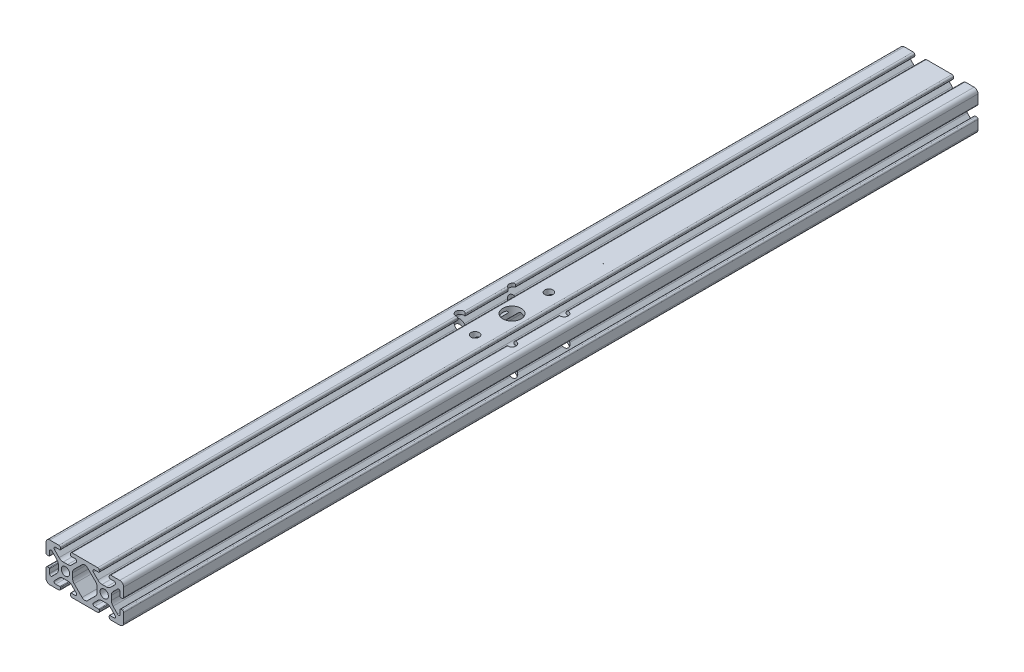
from build123d import *

# Parameters (mm, degrees)
SKIZZE1_R                       = 2.15
AUFSATZ_LINEAR_AUSTRAGEN1_DEPTH = 440
SKIZZE2_R                       = 4.747316715
SCHNITT_LINEAR_AUSTRAGEN1_DEPTH = 21
M5_GEWINDEBOHRUNG1_D            = 4.2


with BuildPart() as part:
    # Skizze1 → Aufsatz-Linear austragen1 (new body)
    with BuildSketch(Plane.XY.offset(1000)):
        with BuildLine():
            Line((24.824997674, -12.875), (24.824997674, -15.044122712))
            ThreePointArc((24.824997674, -15.044122712), (24.343490565, -15.764748956), (23.49345395, -15.595666041))
            Line((23.49345395, -15.595666041), (21.153677342, -13.25588859))
            ThreePointArc((21.153677342, -13.25588859), (20.503359366, -12.282618676), (20.274998067, -11.134568629))
            Line((20.274998067, -11.134568629), (20.274998067, -8.865431267))
            ThreePointArc((20.274998067, -8.865431267), (20.503359366, -7.717381221), (21.153677339, -6.744111308))
            Line((21.153677339, -6.744111308), (23.493453719, -4.404334079))
            ThreePointArc((23.493453719, -4.404334079), (24.343490481, -4.235251133), (24.824997674, -4.955877502))
            Line((24.824997674, -4.955877502), (24.824997674, -7.124999805))
            ThreePointArc((24.824997674, -7.124999805), (24.912865697, -7.337131977), (25.12499787, -7.425))
            Line((25.12499787, -7.425), (25.825, -7.425))
            ThreePointArc((25.825, -7.425), (26.390685425, -7.190685425), (26.625, -6.625))
            Line((26.625, -6.625), (26.625, -2))
            ThreePointArc((26.625, -2), (26.039213562, -0.585786438), (24.625, 0))
            Line((24.625, 0), (19.999999697, 0))
            ThreePointArc((19.999999697, 0), (19.434314272, -0.234314575), (19.199999697, -0.8))
            Line((19.199999697, -0.8), (19.199999697, -1.499999434))
            ThreePointArc((19.199999697, -1.499999434), (19.287867662, -1.712131468), (19.499999697, -1.799999434))
            Line((19.499999697, -1.799999434), (21.669123246, -1.799999434))
            ThreePointArc((21.669123246, -1.799999434), (22.389750472, -2.281507199), (22.220667326, -3.131544972))
            Line((22.220667326, -3.131544972), (19.880890601, -5.471320847))
            ThreePointArc((19.880890601, -5.471320847), (18.907620688, -6.12163882), (17.759570643, -6.350000119))
            Line((17.759570643, -6.350000119), (15.490432362, -6.350000119))
            ThreePointArc((15.490432362, -6.350000119), (14.342381815, -6.121638613), (13.369111636, -5.47132008))
            Line((13.369111636, -5.47132008), (11.029335023, -3.131542624))
            ThreePointArc((11.029335023, -3.131542624), (10.860252403, -2.281506292), (11.580878411, -1.799999434))
            Line((11.580878411, -1.799999434), (13.749999805, -1.799999434))
            ThreePointArc((13.749999805, -1.799999434), (13.962131977, -1.712131411), (14.05, -1.499999239))
            Line((14.05, -1.499999239), (14.05, -0.8))
            ThreePointArc((14.05, -0.8), (13.815685425, -0.234314575), (13.25, 0))
            Line((13.25, 0), (-3.05e-07, 0))
            ThreePointArc((-3.05e-07, 0), (-0.56568573, -0.234314575), (-0.800000305, -0.8))
            Line((-0.800000305, -0.8), (-0.800000305, -1.499999434))
            ThreePointArc((-0.800000305, -1.499999434), (-0.71213234, -1.712131468), (-0.500000305, -1.799999434))
            Line((-0.500000305, -1.799999434), (1.669123789, -1.799999434))
            ThreePointArc((1.669123789, -1.799999434), (2.389750739, -2.281507015), (2.220667658, -3.131544464))
            Line((2.220667658, -3.131544464), (-0.119109575, -5.471320847))
            ThreePointArc((-0.119109575, -5.471320847), (-1.092379488, -6.12163882), (-2.240429534, -6.350000119))
            Line((-2.240429534, -6.350000119), (-4.50956764, -6.350000119))
            ThreePointArc((-4.50956764, -6.350000119), (-5.657618189, -6.121638612), (-6.630888368, -5.471320077))
            Line((-6.630888368, -5.471320077), (-8.970664973, -3.131542623))
            ThreePointArc((-8.970664973, -3.131542623), (-9.139747592, -2.281506291), (-8.419121584, -1.799999434))
            Line((-8.419121584, -1.799999434), (-6.250000197, -1.799999434))
            ThreePointArc((-6.250000197, -1.799999434), (-6.037868023, -1.712131411), (-5.95, -1.499999237))
            Line((-5.95, -1.499999237), (-5.95, -0.8))
            ThreePointArc((-5.95, -0.8), (-6.184314575, -0.234314575), (-6.75, 0))
            Line((-6.75, 0), (-11.375, 0))
            ThreePointArc((-11.375, 0), (-12.789213562, -0.585786438), (-13.375, -2))
            Line((-13.375, -2), (-13.375, -6.625))
            ThreePointArc((-13.375, -6.625), (-13.140685425, -7.190685425), (-12.575, -7.425))
            Line((-12.575, -7.425), (-11.875000566, -7.425))
            ThreePointArc((-11.875000566, -7.425), (-11.662868532, -7.337132034), (-11.575000566, -7.125))
            Line((-11.575000566, -7.125), (-11.575000566, -4.955878914))
            ThreePointArc((-11.575000566, -4.955878914), (-11.093493588, -4.235252725), (-10.243457043, -4.404335387))
            Line((-10.243457043, -4.404335387), (-7.90367992, -6.744111667))
            ThreePointArc((-7.90367992, -6.744111667), (-7.253361387, -7.717381846), (-7.024999881, -8.865432393))
            Line((-7.024999881, -8.865432393), (-7.024999881, -11.13456764))
            ThreePointArc((-7.024999881, -11.13456764), (-7.253361388, -12.282618189), (-7.903679923, -13.255888368))
            Line((-7.903679923, -13.255888368), (-10.243457377, -15.595664973))
            ThreePointArc((-10.243457377, -15.595664973), (-11.093493709, -15.764747592), (-11.575000566, -15.044121584))
            Line((-11.575000566, -15.044121584), (-11.575000566, -12.875000197))
            ThreePointArc((-11.575000566, -12.875000197), (-11.662868589, -12.662868023), (-11.875000763, -12.575))
            Line((-11.875000763, -12.575), (-12.575, -12.575))
            ThreePointArc((-12.575, -12.575), (-13.140685425, -12.809314575), (-13.375, -13.375))
            Line((-13.375, -13.375), (-13.375, -18))
            ThreePointArc((-13.375, -18), (-12.789213562, -19.414213562), (-11.375, -20))
            Line((-11.375, -20), (-6.75, -20))
            ThreePointArc((-6.75, -20), (-6.184314575, -19.765685425), (-5.95, -19.2))
            Line((-5.95, -19.2), (-5.95, -18.500000763))
            ThreePointArc((-5.95, -18.500000763), (-6.037867966, -18.287868729), (-6.25, -18.200000763))
            Line((-6.25, -18.200000763), (-8.419121391, -18.200000763))
            ThreePointArc((-8.419121391, -18.200000763), (-9.13974758, -17.718493784), (-8.970664918, -16.868457239))
            Line((-8.970664918, -16.868457239), (-6.630888309, -14.528679787))
            ThreePointArc((-6.630888309, -14.528679787), (-5.65761813, -13.878361254), (-4.509567583, -13.649999749))
            Line((-4.509567583, -13.649999749), (-2.24042972, -13.649999749))
            ThreePointArc((-2.24042972, -13.649999749), (-1.092379673, -13.878361048), (-0.11910976, -14.528679023))
            Line((-0.11910976, -14.528679023), (2.220668033, -16.868455972))
            ThreePointArc((2.220668033, -16.868455972), (2.389751083, -17.718493268), (1.669124262, -18.200000763))
            Line((1.669124262, -18.200000763), (-0.500000109, -18.200000763))
            ThreePointArc((-0.500000109, -18.200000763), (-0.712132282, -18.287868786), (-0.800000305, -18.50000096))
            Line((-0.800000305, -18.50000096), (-0.800000305, -19.2))
            ThreePointArc((-0.800000305, -19.2), (-0.56568573, -19.765685425), (-3.05e-07, -20))
            Line((-3.05e-07, -20), (13.25, -20))
            ThreePointArc((13.25, -20), (13.815685425, -19.765685425), (14.05, -19.2))
            Line((14.05, -19.2), (14.05, -18.500000763))
            ThreePointArc((14.05, -18.500000763), (13.962132034, -18.287868729), (13.75, -18.200000763))
            Line((13.75, -18.200000763), (11.580878614, -18.200000763))
            ThreePointArc((11.580878614, -18.200000763), (10.860252424, -17.718493784), (11.029335085, -16.868457238))
            Line((11.029335085, -16.868457238), (13.369111683, -14.52867979))
            ThreePointArc((13.369111683, -14.52867979), (14.342381863, -13.878361255), (15.490432412, -13.649999749))
            Line((15.490432412, -13.649999749), (17.759570633, -13.649999749))
            ThreePointArc((17.759570633, -13.649999749), (18.907620681, -13.878361048), (19.880890596, -14.528679023))
            Line((19.880890596, -14.528679023), (22.220667763, -16.868455348))
            ThreePointArc((22.220667763, -16.868455348), (22.389750893, -17.718493043), (21.669123734, -18.200000763))
            Line((21.669123734, -18.200000763), (19.499999892, -18.200000763))
            ThreePointArc((19.499999892, -18.200000763), (19.287867719, -18.287868786), (19.199999697, -18.500000958))
            Line((19.199999697, -18.500000958), (19.199999697, -19.2))
            ThreePointArc((19.199999697, -19.2), (19.434314272, -19.765685425), (19.999999697, -20))
            Line((19.999999697, -20), (24.625, -20))
            ThreePointArc((24.625, -20), (26.039213562, -19.414213562), (26.625, -18))
            Line((26.625, -18), (26.625, -13.375))
            ThreePointArc((26.625, -13.375), (26.390685425, -12.809314575), (25.825, -12.575))
            Line((25.825, -12.575), (25.124997674, -12.575))
            ThreePointArc((25.124997674, -12.575), (24.91286564, -12.662867966), (24.824997674, -12.875))
        make_face()
        with Locations((-3.375, -10)):
            Circle(SKIZZE1_R, mode=Mode.SUBTRACT)
        with Locations((16.625, -10)):
            Circle(SKIZZE1_R, mode=Mode.SUBTRACT)
        with BuildLine():
            Line((12.974998054, -8.865429973), (12.974998054, -11.134569882))
            ThreePointArc((12.974998054, -11.134569882), (12.746636547, -12.28262043), (12.096318012, -13.25589061))
            Line((12.096318012, -13.25589061), (8.039210508, -17.312996641))
            ThreePointArc((8.039210508, -17.312996641), (6.624996839, -17.898782822), (5.210783383, -17.312996128))
            Line((5.210783383, -17.312996128), (1.153677326, -13.255888598))
            ThreePointArc((1.153677326, -13.255888598), (0.503359352, -12.282618685), (0.274998054, -11.134568639))
            Line((0.274998054, -11.134568639), (0.274998054, -8.865431307))
            ThreePointArc((0.274998054, -8.865431307), (0.503359353, -7.717381259), (1.153677329, -6.744111345))
            Line((1.153677329, -6.744111345), (5.210783442, -2.68700377))
            ThreePointArc((5.210783442, -2.68700377), (6.624996899, -2.101217078), (8.039210567, -2.687003261))
            Line((8.039210567, -2.687003261), (12.096318015, -6.744109247))
            ThreePointArc((12.096318015, -6.744109247), (12.746636548, -7.717379426), (12.974998054, -8.865429973))
        make_face(mode=Mode.SUBTRACT)
    extrude(amount=-AUFSATZ_LINEAR_AUSTRAGEN1_DEPTH)

    # Skizze2 → Schnitt-Linear austragen1 (cut, through all)
    with BuildSketch(Plane(origin=(0, 0, 0), x_dir=(1, 0, 0), z_dir=(0, 1, 0))):
        with Locations((6.625, -780)):
            Circle(SKIZZE2_R)
    extrude(amount=-SCHNITT_LINEAR_AUSTRAGEN1_DEPTH, mode=Mode.SUBTRACT)

    # M5 Gewindebohrung1 (through all)
    with Locations(Plane(origin=(0, -20, 0), x_dir=(-1, 0, 0), z_dir=(0, -1, 0))):
        with Locations((-6.625, -799), (-20.060028843, -793.435028843), (6.810028843, -793.435028843), (-6.625, -761), (-20.060028843, -766.564971157), (5.241251753, -767.485569481)):
            Hole(M5_GEWINDEBOHRUNG1_D / 2)


solid = part.part
